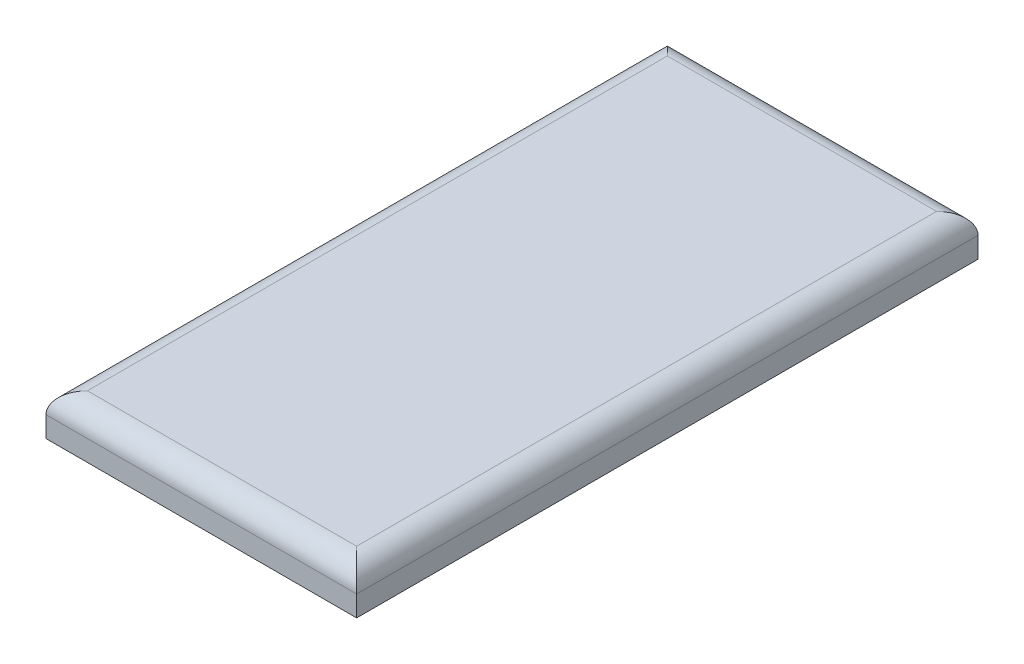
from build123d import *

# Parameters (mm, degrees)
SKETCH1_W           = 150
SKETCH1_H           = 300
BOSS_EXTRUDE1_DEPTH = 20
FILLET1_R           = 10


with BuildPart() as part:
    # Sketch1 → Boss-Extrude1 (new body)
    with BuildSketch(Plane(origin=(0, 0, 0), x_dir=(1, 0, 0), z_dir=(0, 1, 0))):
        Rectangle(SKETCH1_W, SKETCH1_H)
    extrude(amount=BOSS_EXTRUDE1_DEPTH)

    # Fillet1
    fillet1_edges = [part.edges().sort_by_distance(p)[0] for p in [
        (-75, 20, 0),
        (0, 20, 150),
        (75, 20, 0),
        (0, 20, -150),
    ]]
    fillet(fillet1_edges, radius=FILLET1_R)


solid = part.part
